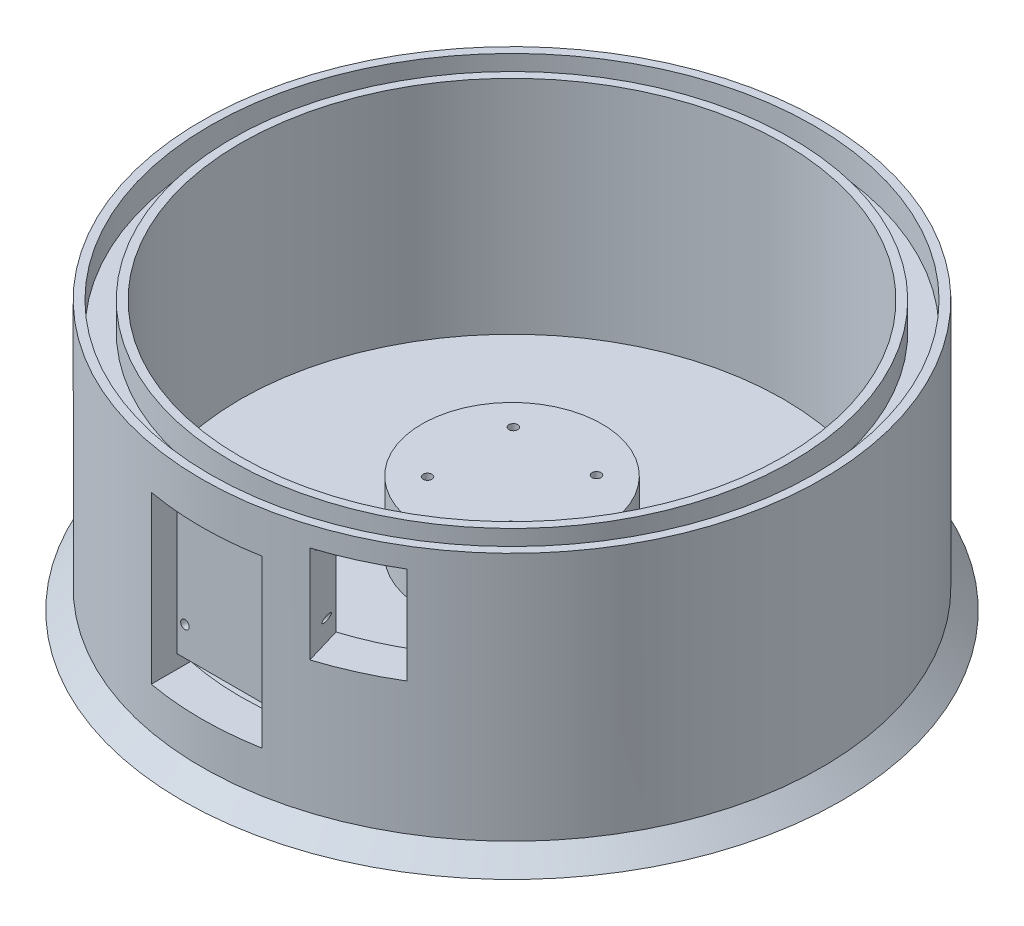
from build123d import *

# Parameters (mm, degrees)
SKETCH1_R               = 112
BOSS_EXTRUDE3_DEPTH     = 90
SKETCH9_R               = 109
SKETCH9_R_2             = 101
CUT_EXTRUDE6_DEPTH      = 10
SKETCH4_W               = 40
SKETCH4_H               = 60
CUT_EXTRUDE2_DEPTH      = 26
CUT_EXTRUDE2_DEPTH_BACK = 4
SKETCH12_R              = 112
BOSS_EXTRUDE4_DEPTH     = 7
BOSS_EXTRUDE4_TAPER     = -45
SKETCH13_R              = 98
CUT_EXTRUDE8_DEPTH      = 80
SKETCH14_R              = 0.75
CUT_EXTRUDE9_DEPTH      = 15
SKETCH18_R              = 32.5
BOSS_EXTRUDE5_DEPTH     = 25
SKETCH16_R              = 1.6
CUT_EXTRUDE11_DEPTH     = 98.0000001
SKETCH17_R              = 3
CUT_EXTRUDE12_DEPTH     = 30
SKETCH19_R              = 30
CUT_EXTRUDE13_DEPTH     = 25
SKETCH20_W              = 40
SKETCH20_H              = 5
CUT_EXTRUDE14_DEPTH     = 25
SKETCH21_R              = 1.55
CUT_EXTRUDE15_DEPTH     = 25
CUT_EXTRUDE16_DEPTH     = 35


with BuildPart() as part:
    # Sketch1 → Boss-Extrude3 (new body)
    with BuildSketch(Plane(origin=(0, 0, 0), x_dir=(1, 0, 0), z_dir=(0, 1, 0))):
        Circle(SKETCH1_R)
    extrude(amount=BOSS_EXTRUDE3_DEPTH)

    # Sketch9 → Cut-Extrude6 (cut)
    with BuildSketch(Plane(origin=(0, 90, 0), x_dir=(1, 0, 0), z_dir=(0, 1, 0))):
        Circle(SKETCH9_R)
        Circle(SKETCH9_R_2, mode=Mode.SUBTRACT)
    extrude(amount=-CUT_EXTRUDE6_DEPTH, mode=Mode.SUBTRACT)

    # Sketch4 → Cut-Extrude2 (cut, two sides)
    with BuildSketch(Plane.XY.offset(105)) as cut_extrude2_sk:
        with Locations((0, 45)):
            Rectangle(SKETCH4_W, SKETCH4_H)
    extrude(amount=CUT_EXTRUDE2_DEPTH, mode=Mode.SUBTRACT)
    extrude(cut_extrude2_sk.sketch, amount=-CUT_EXTRUDE2_DEPTH_BACK, mode=Mode.SUBTRACT)

    # Sketch12 → Boss-Extrude4 (add)
    with BuildSketch(Plane.XZ):
        Circle(SKETCH12_R)
    extrude(amount=BOSS_EXTRUDE4_DEPTH, taper=BOSS_EXTRUDE4_TAPER)

    # Sketch13 → Cut-Extrude8 (cut)
    with BuildSketch(Plane(origin=(0, 90, 0), x_dir=(1, 0, 0), z_dir=(0, 1, 0))):
        Circle(SKETCH13_R)
    extrude(amount=-CUT_EXTRUDE8_DEPTH, mode=Mode.SUBTRACT)

    # Sketch14 → Cut-Extrude9 (cut)
    with BuildSketch(Plane.XY.offset(101)):
        with Locations((-31.25, 55.25)):
            Circle(SKETCH14_R)
        with Locations((31.25, 55.25)):
            Circle(SKETCH14_R)
        with Locations((31.25, 7.75)):
            Circle(SKETCH14_R)
        with Locations((-31.25, 7.75)):
            Circle(SKETCH14_R)
    extrude(amount=-CUT_EXTRUDE9_DEPTH, mode=Mode.SUBTRACT)

    # Sketch18 → Boss-Extrude5 (add)
    with BuildSketch(Plane(origin=(0, 10, 0), x_dir=(1, 0, 0), z_dir=(0, 1, 0))):
        Circle(SKETCH18_R)
    extrude(amount=BOSS_EXTRUDE5_DEPTH)

    # Sketch16 → Cut-Extrude11 (cut, through all)
    with BuildSketch(Plane.XZ.offset(7)):
        with Locations((-15, 15.5)):
            Circle(SKETCH16_R)
        with Locations((15, 15.5)):
            Circle(SKETCH16_R)
        with Locations((15, -15.5)):
            Circle(SKETCH16_R)
        with Locations((-15, -15.5)):
            Circle(SKETCH16_R)
    extrude(amount=-CUT_EXTRUDE11_DEPTH, mode=Mode.SUBTRACT)

    # Sketch17 → Cut-Extrude12 (cut)
    with BuildSketch(Plane.XZ.offset(7)):
        with Locations((-15, 15.5)):
            Circle(SKETCH17_R)
        with Locations((15, 15.5)):
            Circle(SKETCH17_R)
        with Locations((-15, -15.5)):
            Circle(SKETCH17_R)
        with Locations((15, -15.5)):
            Circle(SKETCH17_R)
    extrude(amount=-CUT_EXTRUDE12_DEPTH, mode=Mode.SUBTRACT)

    # Sketch19 → Cut-Extrude13 (cut)
    with BuildSketch(Plane.XZ.offset(7)):
        Circle(SKETCH19_R)
    extrude(amount=-CUT_EXTRUDE13_DEPTH, mode=Mode.SUBTRACT)

    # Sketch20 → Cut-Extrude14 (cut)
    with BuildSketch(Plane.XY.offset(101)):
        with Locations((0, 17.5)):
            Rectangle(SKETCH20_W, SKETCH20_H)
    extrude(amount=-CUT_EXTRUDE14_DEPTH, mode=Mode.SUBTRACT)

    # Sketch21 → Cut-Extrude15 (cut)
    with BuildSketch(Plane.XY.offset(101)):
        with Locations((12.45, 67.8)):
            Circle(SKETCH21_R)
        with Locations((-12.45, 67.8)):
            Circle(SKETCH21_R)
        with Locations((-17.05, 30.54)):
            Circle(SKETCH21_R)
        with Locations((17.05, 30.54)):
            Circle(SKETCH21_R)
    extrude(amount=-CUT_EXTRUDE15_DEPTH, mode=Mode.SUBTRACT)

    # Sketch22 → Cut-Extrude16 (cut)
    with BuildSketch(Plane(origin=(22.204096953, 47.794122581, -296.404157649), x_dir=(1, 0, 0), z_dir=(0, 1, 0))):
        Polygon((-8.101888311, -337.261049447), (12.404969277, -405.762485644), (37.058002756, -394.3841625), (-1.388931435, -334.195344764), align=None)
    extrude(amount=CUT_EXTRUDE16_DEPTH, mode=Mode.SUBTRACT)


solid = part.part
